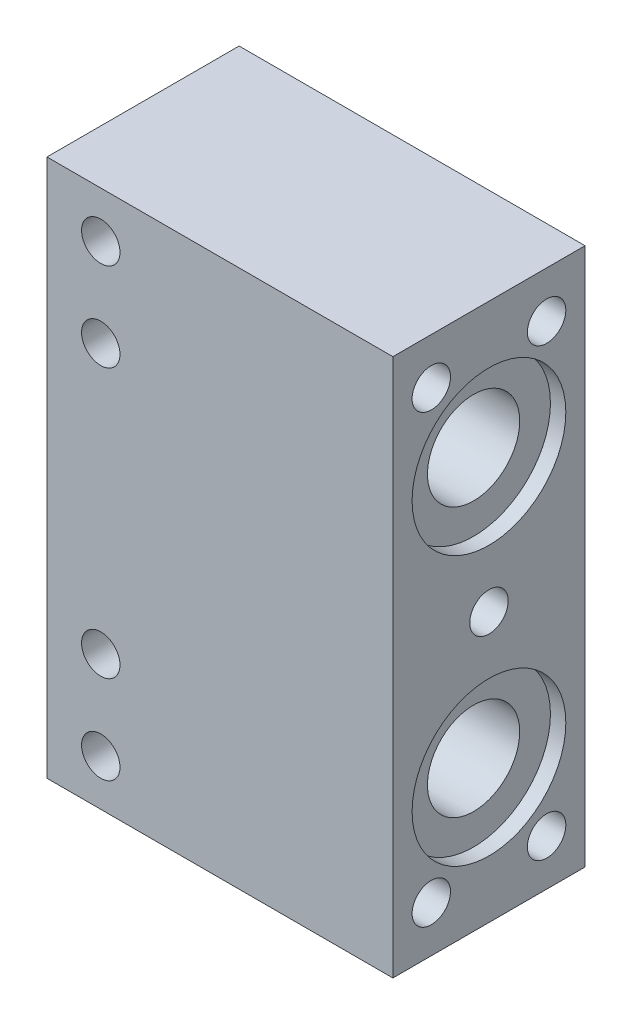
from build123d import *

# Parameters (mm, degrees)
SKETCH1_W           = 45
SKETCH1_H           = 25
BOSS_EXTRUDE1_DEPTH = 70
SKETCH2_R           = 6
CUT_EXTRUDE1_DEPTH  = 70
SKETCH3_R           = 10
CUT_EXTRUDE2_DEPTH  = 2
SKETCH4_R           = 10
CUT_EXTRUDE3_DEPTH  = 2
SKETCH5_R           = 2.5
CUT_EXTRUDE4_DEPTH  = 15
SKETCH6_R           = 2.5
CUT_EXTRUDE5_DEPTH  = 15
SKETCH7_R           = 2.5
CUT_EXTRUDE6_DEPTH  = 36
SKETCH8_R           = 2.5
CUT_EXTRUDE7_DEPTH  = 38


with BuildPart() as part:
    # Sketch1 → Boss-Extrude1 (new body)
    with BuildSketch(Plane(origin=(0, 0, 0), x_dir=(1, 0, 0), z_dir=(0, 1, 0))):
        Rectangle(SKETCH1_W, SKETCH1_H)
    extrude(amount=BOSS_EXTRUDE1_DEPTH)

    # Sketch2 → Cut-Extrude1 (cut)
    with BuildSketch(Plane(origin=(22.5, 0, 0), x_dir=(0, 0, -1), z_dir=(1, 0, 0))):
        with Locations((0, 52.5)):
            Circle(SKETCH2_R)
        with Locations((0, 17.5)):
            Circle(SKETCH2_R)
    extrude(amount=-CUT_EXTRUDE1_DEPTH, mode=Mode.SUBTRACT)

    # Sketch3 → Cut-Extrude2 (cut)
    with BuildSketch(Plane(origin=(22.5, 0, 0), x_dir=(0, 0, -1), z_dir=(1, 0, 0))):
        with Locations((0, 17.5)):
            Circle(SKETCH3_R)
        with Locations((0, 52.5)):
            Circle(SKETCH3_R)
    extrude(amount=-CUT_EXTRUDE2_DEPTH, mode=Mode.SUBTRACT)

    # Sketch4 → Cut-Extrude3 (cut)
    with BuildSketch(Plane.ZY.offset(22.5)):
        with Locations((0, 52.5)):
            Circle(SKETCH4_R)
        with Locations((0, 17.5)):
            Circle(SKETCH4_R)
    extrude(amount=-CUT_EXTRUDE3_DEPTH, mode=Mode.SUBTRACT)

    # Sketch5 → Cut-Extrude4 (cut)
    with BuildSketch(Plane(origin=(22.5, 0, 0), x_dir=(0, 0, -1), z_dir=(1, 0, 0))):
        with Locations((7.5, 6)):
            Circle(SKETCH5_R)
        with Locations((-7.5, 6)):
            Circle(SKETCH5_R)
        with Locations((7.5, 64)):
            Circle(SKETCH5_R)
        with Locations((-7.5, 64)):
            Circle(SKETCH5_R)
    extrude(amount=-CUT_EXTRUDE4_DEPTH, mode=Mode.SUBTRACT)

    # Sketch6 → Cut-Extrude5 (cut)
    with BuildSketch(Plane(origin=(22.5, 0, 0), x_dir=(0, 0, -1), z_dir=(1, 0, 0))):
        with Locations((0, 35)):
            Circle(SKETCH6_R)
    extrude(amount=-CUT_EXTRUDE5_DEPTH, mode=Mode.SUBTRACT)

    # Sketch7 → Cut-Extrude6 (cut)
    with BuildSketch(Plane.XY.offset(12.5)):
        with Locations((-15.5, 52.5)):
            Circle(SKETCH7_R)
        with Locations((-15.5, 17.5)):
            Circle(SKETCH7_R)
    extrude(amount=-CUT_EXTRUDE6_DEPTH, mode=Mode.SUBTRACT)

    # Sketch8 → Cut-Extrude7 (cut)
    with BuildSketch(Plane.XY.offset(12.5)):
        with Locations((-15.5, 64)):
            Circle(SKETCH8_R)
        with Locations((-15.5, 6)):
            Circle(SKETCH8_R)
    extrude(amount=-CUT_EXTRUDE7_DEPTH, mode=Mode.SUBTRACT)


solid = part.part
